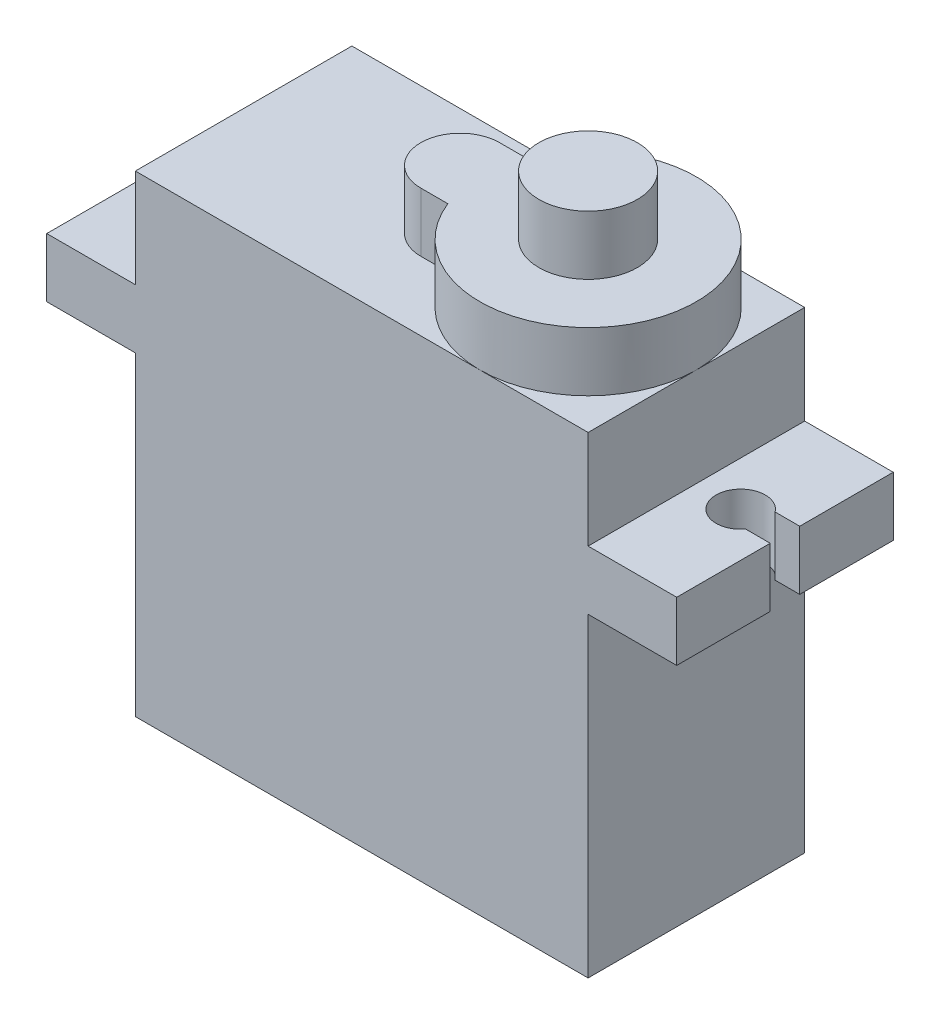
from build123d import *

# Parameters (mm, degrees)
SKETCH1_W                = 23
SKETCH1_H                = 11
BOSS_EXTRUDE1_DEPTH      = 24
SKETCH2_W                = 11
SKETCH2_H                = 3
BOSS_EXTRUDE2_DEPTH      = 4.5
BOSS_EXTRUDE2_DEPTH_BACK = 27.5
SKETCH3_R                = 2.5
BOSS_EXTRUDE3_DEPTH      = 3
SKETCH4_R                = 2.5
BOSS_EXTRUDE4_DEPTH      = 3
BOSS_EXTRUDE4_DEPTH_BACK = 27
CUT_EXTRUDE1_DEPTH       = 4


with BuildPart() as part:
    # Sketch1 → Boss-Extrude1 (new body)
    with BuildSketch(Plane(origin=(0, 0, 0), x_dir=(1, 0, 0), z_dir=(0, 1, 0))):
        Rectangle(SKETCH1_W, SKETCH1_H)
    extrude(amount=BOSS_EXTRUDE1_DEPTH)

    # Sketch2 → Boss-Extrude2 (add, two sides)
    with BuildSketch(Plane(origin=(11.5, 0, 0), x_dir=(0, 0, -1), z_dir=(1, 0, 0))) as boss_extrude2_sk:
        with Locations((0, 17.5)):
            Rectangle(SKETCH2_W, SKETCH2_H)
    extrude(amount=BOSS_EXTRUDE2_DEPTH)
    extrude(boss_extrude2_sk.sketch, amount=-BOSS_EXTRUDE2_DEPTH_BACK)

    # Sketch3 → Boss-Extrude3 (add)
    with BuildSketch(Plane(origin=(0, 24, 0), x_dir=(1, 0, 0), z_dir=(0, 1, 0))):
        with BuildLine():
            Line((-0.5, 2), (0.876524617, 2))
            ThreePointArc((0.876524617, 2), (11.5, 0), (0.876524617, -2))
            Line((0.876524617, -2), (-0.5, -2))
            ThreePointArc((-0.5, -2), (-2.5, 0), (-0.5, 2))
        make_face()
        with Locations((6, 0)):
            Circle(SKETCH3_R, mode=Mode.SUBTRACT)
    extrude(amount=BOSS_EXTRUDE3_DEPTH)

    # Sketch4 → Boss-Extrude4 (add, two sides)
    with BuildSketch(Plane(origin=(0, 27, 0), x_dir=(1, 0, 0), z_dir=(0, 1, 0))) as boss_extrude4_sk:
        with Locations((6, 0)):
            Circle(SKETCH4_R)
    extrude(amount=BOSS_EXTRUDE4_DEPTH)
    extrude(boss_extrude4_sk.sketch, amount=-BOSS_EXTRUDE4_DEPTH_BACK)

    # Sketch5 → Cut-Extrude1 (cut)
    with BuildSketch(Plane(origin=(0, 19, 0), x_dir=(1, 0, 0), z_dir=(0, 1, 0))):
        with BuildLine():
            Line((-16, -0.75), (-14.75, -0.75))
            ThreePointArc((-14.75, -0.75), (-12.5, 0), (-14.75, 0.75))
            Line((-14.75, 0.75), (-16, 0.75))
            Line((-16, 0.75), (-16, -0.75))
        make_face()
        with BuildLine():
            Line((14.75, 0.75), (16, 0.75))
            Line((16, 0.75), (16, -0.75))
            Line((16, -0.75), (14.75, -0.75))
            ThreePointArc((14.75, -0.75), (12.5, 0), (14.75, 0.75))
        make_face()
    extrude(amount=-CUT_EXTRUDE1_DEPTH, mode=Mode.SUBTRACT)


solid = part.part
